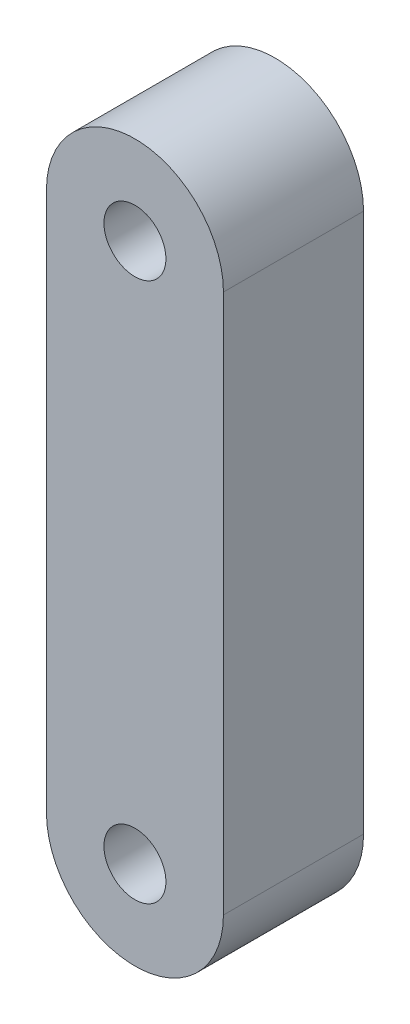
from build123d import *

# Parameters (mm, degrees)
ESBO_O1_R                = 2.1
RESSALTO_EXTRUS_O1_DEPTH = 9.5


with BuildPart() as part:
    # Esboço1 → Ressalto-extrusão1 (new body)
    with BuildSketch(Plane.XY.offset(9.5)):
        with BuildLine():
            Line((-77.652318909, -56.622659468), (-77.652318909, -20.044841126))
            ThreePointArc((-77.652318909, -20.044841126), (-83.652318909, -14.044841126), (-89.652318909, -20.044841126))
            Line((-89.652318909, -20.044841126), (-89.652318909, -56.622659468))
            ThreePointArc((-89.652318909, -56.622659468), (-83.652318909, -62.622659468), (-77.652318909, -56.622659468))
        make_face()
        with Locations((-83.652318909, -56.622659468)):
            Circle(ESBO_O1_R, mode=Mode.SUBTRACT)
        with Locations((-83.652318909, -20.044841126)):
            Circle(ESBO_O1_R, mode=Mode.SUBTRACT)
    extrude(amount=-RESSALTO_EXTRUS_O1_DEPTH)


solid = part.part
